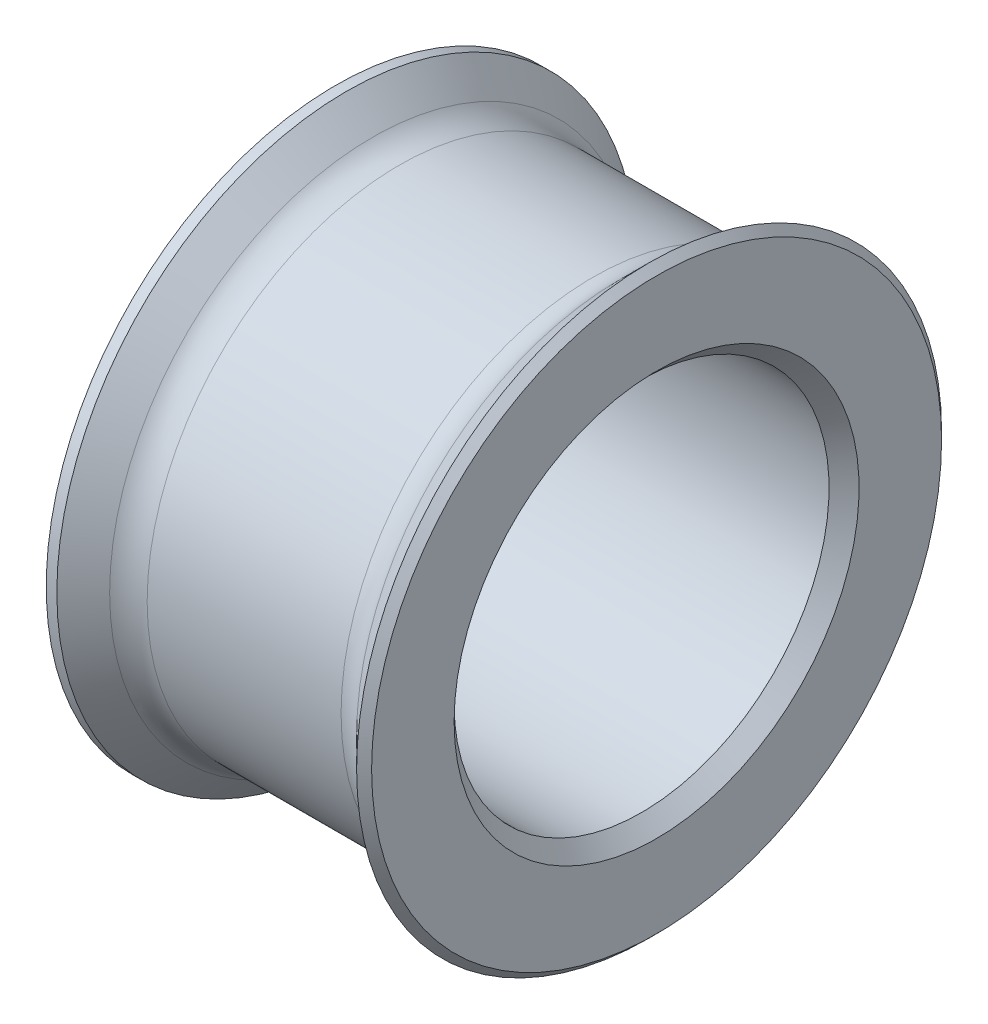
from build123d import *
from OCP.BRepFilletAPI import BRepFilletAPI_MakeChamfer

# Parameters (mm, degrees)
CHAMFER1_SIZE  = 0.2
CHAMFER1_SIZE2 = 0.141421356
FILLET1_R      = 0.5


with BuildPart() as part:
    # Sketch1 → Revolve1 (revolve)
    with BuildSketch(Plane.XY, mode=Mode.PRIVATE) as revolve1_sk:
        Polygon((0, 3.36), (1.5, 3.36), (2.14, 4), (2.14, 2.5), (-2.14, 2.5), (-2.14, 4), (-1.5, 3.36), align=None)
    revolve(revolve1_sk.sketch.rotate(Axis((0, 0, 0), (1, 0, 0)), 90), axis=Axis((0, 0, 0), (1, 0, 0)))

    # Chamfer1: one chamfer whose edges measure the first distance from different faces: ONE call of the kernel's chamfer builder (chamfer() names one face for all edges)
    chamfer1_edges_1 = [part.edges().sort_by_distance(p)[0] for p in [
        (-2.14, 0, -4),
    ]]
    chamfer1_side_1 = [part.faces().sort_by_distance(p)[0] for p in [
        (-1.82, 0, -3.68),
    ]]
    chamfer1_edges_2 = [part.edges().sort_by_distance(p)[0] for p in [
        (-2.14, 0, -2.5),
        (2.14, 0, -2.5),
    ]]
    chamfer1_edges_3 = [part.edges().sort_by_distance(p)[0] for p in [
        (2.14, 0, -4),
    ]]
    chamfer1_side_3 = [part.faces().sort_by_distance(p)[0] for p in [
        (2.14, 0, -3.886862915),
    ]]
    chamfer1 = BRepFilletAPI_MakeChamfer(part.part.solid().wrapped)
    for e in chamfer1_edges_1:
        chamfer1.Add(CHAMFER1_SIZE, CHAMFER1_SIZE2, e.wrapped, chamfer1_side_1[0].wrapped)  # the first distance lies on this face
    for e in chamfer1_edges_2:
        chamfer1.Add(CHAMFER1_SIZE, e.wrapped)
    for e in chamfer1_edges_3:
        chamfer1.Add(CHAMFER1_SIZE, CHAMFER1_SIZE2, e.wrapped, chamfer1_side_3[0].wrapped)  # the first distance lies on this face
    add(Compound.cast(chamfer1.Shape()), mode=Mode.REPLACE)

    # Fillet1
    fillet1_edges = [part.edges().sort_by_distance(p)[0] for p in [
        (-1.5, 0, -3.36),
        (1.5, 0, -3.36),
    ]]
    fillet(fillet1_edges, radius=FILLET1_R)


solid = part.part
